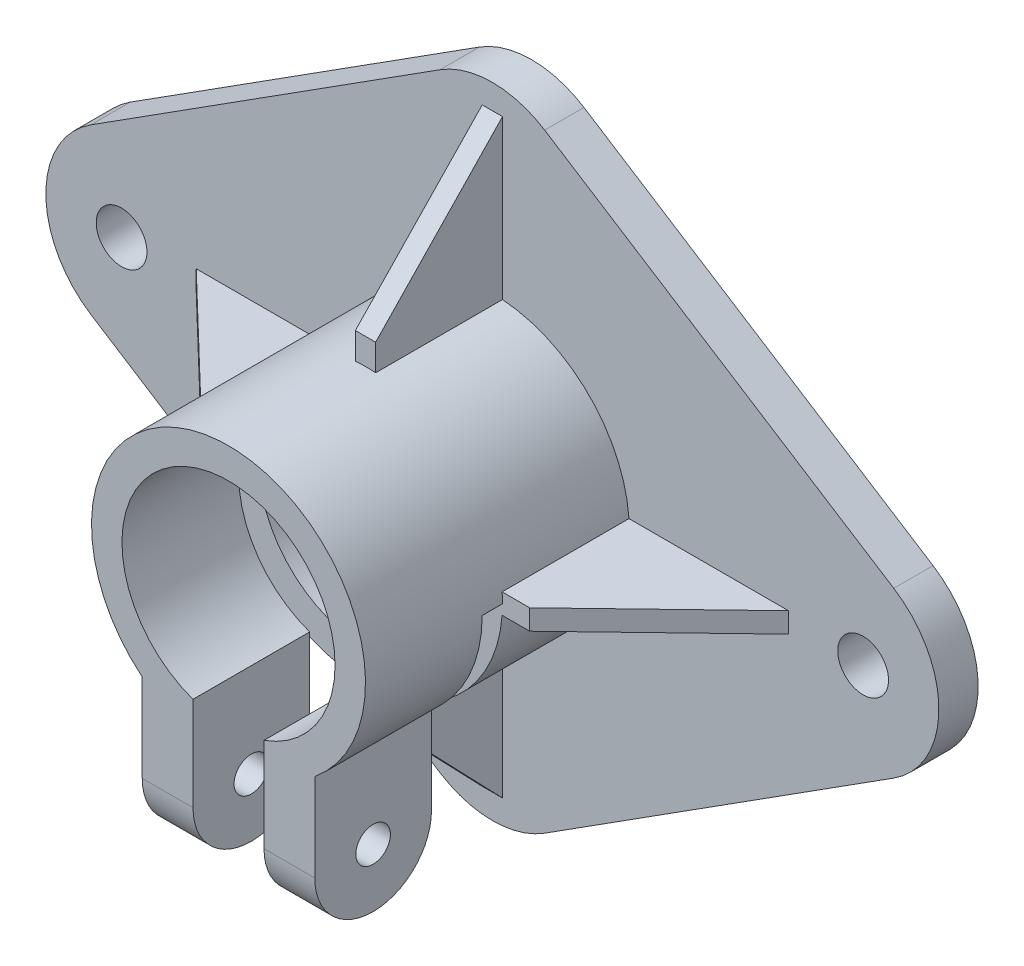
from build123d import *

# Parameters (mm, degrees)
SKETCH1_R             = 8.334375
BOSS_EXTRUDE1_DEPTH   = 3.0734
F_6_CLEARANCE_HOLE1_D = 3.96875
SKETCH4_R             = 10.715625
SKETCH4_R_2           = 8.334375
BOSS_EXTRUDE2_DEPTH   = 20.6375
CUT_EXTRUDE1_DEPTH    = 26.003125
SKETCH7_W             = 3.96875
SKETCH7_H             = 9.128125
BOSS_EXTRUDE3_DEPTH   = 11.90625
CUT_EXTRUDE2_DEPTH    = 42.671875
F_2_CLEARANCE_HOLE1_D = 2.7051
BOSS_EXTRUDE7_DEPTH   = 0.79375
BOSS_EXTRUDE8_DEPTH   = 0.79375


with BuildPart() as part:
    # Sketch1 → Boss-Extrude1 (new body)
    with BuildSketch(Plane.XY):
        with BuildLine():
            Line((-31.397200262, 6.427931006), (-4.092200262, 23.811056006))
            ThreePointArc((-4.092200262, 23.811056006), (0, 25.003125), (4.092200262, 23.811056006))
            Line((4.092200262, 23.811056006), (31.397200262, 6.427931006))
            ThreePointArc((31.397200262, 6.427931006), (34.925, 0), (31.397200262, -6.427931006))
            Line((31.397200262, -6.427931006), (4.092200262, -23.811056006))
            ThreePointArc((4.092200262, -23.811056006), (0, -25.003125), (-4.092200262, -23.811056006))
            Line((-4.092200262, -23.811056006), (-31.397200262, -6.427931006))
            ThreePointArc((-31.397200262, -6.427931006), (-34.925, 0), (-31.397200262, 6.427931006))
        make_face()
        Circle(SKETCH1_R, mode=Mode.SUBTRACT)
    extrude(amount=BOSS_EXTRUDE1_DEPTH)

    # #6 Clearance Hole1 (through all)
    with Locations(Plane.XY.offset(3.0734)):
        with Locations((-29, 0), (29, 0)):
            Hole(F_6_CLEARANCE_HOLE1_D / 2)

    # Sketch4 → Boss-Extrude2 (add)
    with BuildSketch(Plane.XY.offset(3.0734)):
        Circle(SKETCH4_R)
        Circle(SKETCH4_R_2, mode=Mode.SUBTRACT)
    extrude(amount=BOSS_EXTRUDE2_DEPTH)

    # Sketch6 → Cut-Extrude1 (cut, through all)
    with BuildSketch(Plane(origin=(0, 0, 0), x_dir=(1, 0, 0), z_dir=(0, 1, 0))):
        Polygon((-10.715625, -12.995275), (10.715625, -12.995275), (10.715625, -14.582775), (2.778125, -14.582775), (2.778125, -23.7109), (-2.778125, -23.7109), (-2.778125, -14.582775), (-10.715625, -14.582775), align=None)
    extrude(amount=-CUT_EXTRUDE1_DEPTH, mode=Mode.SUBTRACT)

    # Sketch7 → Boss-Extrude3 (add)
    with BuildSketch(Plane(origin=(0, -7.857724106, 0), x_dir=(1, 0, 0), z_dir=(0, 1, 0))):
        with Locations((-4.7625, -19.1468375)):
            Rectangle(SKETCH7_W, SKETCH7_H)
        with Locations((4.7625, -19.1468375)):
            Rectangle(SKETCH7_W, SKETCH7_H)
    extrude(amount=-BOSS_EXTRUDE3_DEPTH)

    # Sketch8 → Cut-Extrude2 (cut, through all)
    with BuildSketch(Plane.ZY.offset(6.746875)):
        with BuildLine():
            Line((23.7109, -15.199911606), (23.7109, -21.050205541))
            Line((23.7109, -21.050205541), (14.582775, -21.050205541))
            Line((14.582775, -21.050205541), (14.582775, -15.199911606))
            ThreePointArc((14.582775, -15.199911606), (19.1468375, -19.763974106), (23.7109, -15.199911606))
        make_face()
    extrude(amount=-CUT_EXTRUDE2_DEPTH, mode=Mode.SUBTRACT)

    # #2 Clearance Hole1 (through all)
    with Locations(Plane.ZY.offset(6.746875)):
        with Locations((19.1468375, -15.199911606)):
            Hole(F_2_CLEARANCE_HOLE1_D / 2)

    # Sketch11 → Boss-Extrude7 (add, symmetric)
    with BuildSketch(Plane(origin=(0, 0, 0), x_dir=(1, 0, 0), z_dir=(0, 1, 0))):
        Polygon((-10.461625, -12.995275), (-12.842875, -12.995275), (-23.161625, -3.0734), (-10.461625, -3.0734), align=None)
        Polygon((23.161625, -3.0734), (10.461625, -3.0734), (10.461625, -12.995275), (12.842875, -12.995275), align=None)
    extrude(amount=BOSS_EXTRUDE7_DEPTH, both=True)

    # Sketch13 → Boss-Extrude8 (add, symmetric)
    with BuildSketch(Plane(origin=(0, 0, 0), x_dir=(0, 0, -1), z_dir=(1, 0, 0))):
        Polygon((-12.995275, 10.377516644), (-12.995275, 12.758766644), (-3.0734, 23.077516644), (-3.0734, 10.377516644), align=None)
        Polygon((-3.0734, -23.077516644), (-3.0734, -10.377516644), (-12.995275, -10.377516644), (-12.995275, -12.758766644), align=None)
    extrude(amount=BOSS_EXTRUDE8_DEPTH, both=True)


solid = part.part
